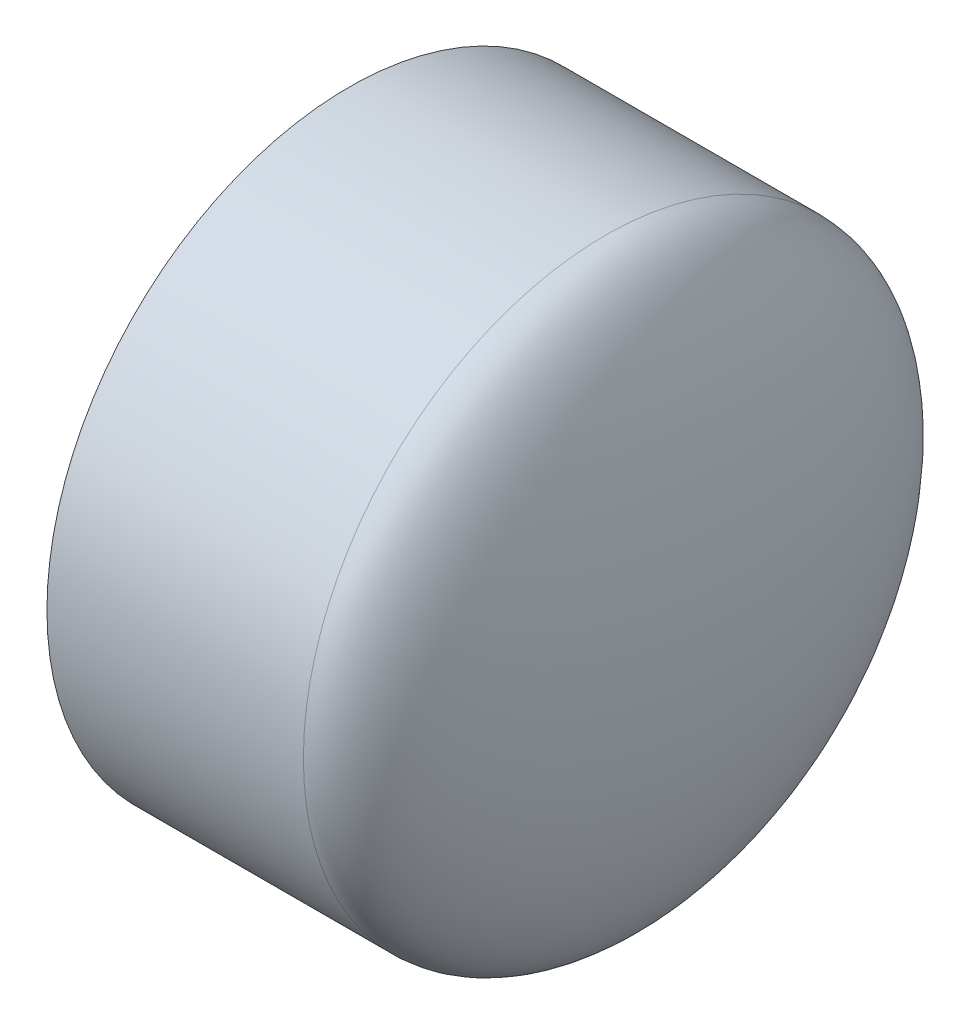
from build123d import *


with BuildPart() as part:
    # Sketch1 → Revolve1 (revolve)
    with BuildSketch(Plane.XY):
        with BuildLine():
            Line((-79.1972, -67.31), (-22.0472, -67.31))
            add(Edge.make_bspline(
                [(-22.0472, -67.31), (0, -67.31), (0, 0)],
                knots=[3.141592654, 3.141592654, 3.141592654, 4.71238898, 4.71238898, 4.71238898], degree=2, weights=[1, 0.707106781, 1]))
            Line((0, 0), (-10.2743, 0))
            add(Edge.make_bspline(
                [(-22.0472, -57.0357), (-10.2743, -57.0357), (-10.2743, 0)],
                knots=[0, 0, 0, 1.570796327, 1.570796327, 1.570796327], degree=2, weights=[1, 0.707106781, 1]))
            Line((-22.0472, -57.0357), (-79.1972, -57.3786))
            Line((-79.1972, -57.3786), (-79.1972, -67.31))
        make_face()
    revolve(axis=Axis((-79.1972, 0, 0), (1, 0, 0)))


solid = part.part
